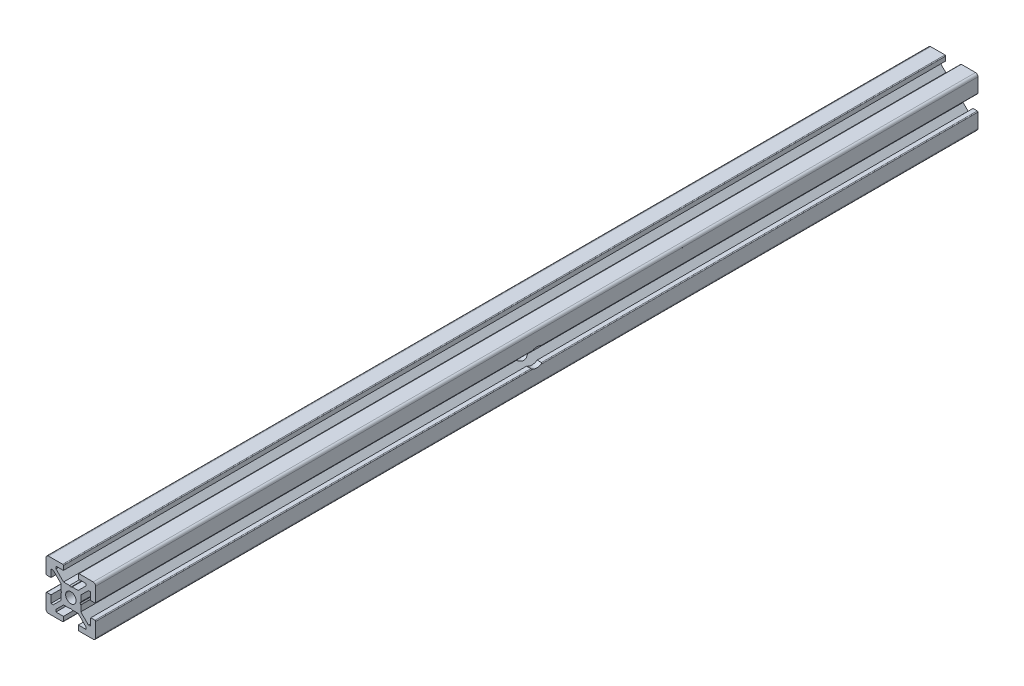
from build123d import *

# Parameters (mm, degrees)
BOSS_EXTRUDE1_DEPTH     = 355
SKETCH2_W               = 355
SKETCH2_H               = 2.1
SKETCH3_R               = 3.6751
CUT_EXTRUDE1_DEPTH      = 10
CUT_EXTRUDE1_DEPTH_BACK = 10


with BuildPart() as part:
    # Sketch1 → Boss-Extrude1 (new body)
    with BuildSketch(Plane.XY):
        with BuildLine():
            Line((-10, 9), (-10, 3.29999995))
            ThreePointArc((-10, 3.29999995), (-9.912132049, 3.087867916), (-9.7, 3))
            Line((-9.7, 3), (-8, 3))
            Line((-8, 3), (-8, 6))
            Line((-8, 6), (-7.060677, 6))
            Line((-7.060677, 6), (-4, 2.93932965))
            Line((-4, 2.93932965), (-4, 0.519615242))
            Line((-4, 0.519615242), (-3.699996283, -6.437e-06))
            Line((-3.699996283, -6.437e-06), (-4, -0.519628117))
            Line((-4, -0.519628117), (-4, -2.93933725))
            Line((-4, -2.93933725), (-7.0606695, -6))
            Line((-7.0606695, -6), (-8, -6))
            Line((-8, -6), (-8, -3))
            Line((-8, -3), (-9.7, -3))
            ThreePointArc((-9.7, -3), (-9.912132049, -3.087867916), (-10, -3.29999995))
            Line((-10, -3.29999995), (-10, -9))
            ThreePointArc((-10, -9), (-9.707106781, -9.707106781), (-9, -10))
            Line((-9, -10), (-3.29999995, -10))
            ThreePointArc((-3.29999995, -10), (-3.087867916, -9.912132049), (-3, -9.7))
            Line((-3, -9.7), (-3, -8))
            Line((-3, -8), (-6, -8))
            Line((-6, -8), (-6, -7.0606515))
            Line((-6, -7.0606515), (-2.9393489, -4))
            Line((-2.9393489, -4), (-0.519615242, -4))
            Line((-0.519615242, -4), (6.437e-06, -3.699996283))
            Line((6.437e-06, -3.699996283), (0.519628117, -4))
            Line((0.519628117, -4), (2.9393227, -4))
            Line((2.9393227, -4), (6, -7.060677))
            Line((6, -7.060677), (6, -8))
            Line((6, -8), (3, -8))
            Line((3, -8), (3, -9.7))
            ThreePointArc((3, -9.7), (3.087867916, -9.912132049), (3.29999995, -10))
            Line((3.29999995, -10), (9, -10))
            ThreePointArc((9, -10), (9.707106781, -9.707106781), (10, -9))
            Line((10, -9), (10, -3.29999995))
            ThreePointArc((10, -3.29999995), (9.912132049, -3.087867916), (9.7, -3))
            Line((9.7, -3), (8, -3))
            Line((8, -3), (8, -6))
            Line((8, -6), (7.0606435, -6))
            Line((7.0606435, -6), (4, -2.9393482))
            Line((4, -2.9393482), (4, -0.519615242))
            Line((4, -0.519615242), (3.699996283, 6.437e-06))
            Line((3.699996283, 6.437e-06), (4, 0.519628117))
            Line((4, 0.519628117), (4, 2.9393401))
            Line((4, 2.9393401), (7.060651, 6))
            Line((7.060651, 6), (8, 6))
            Line((8, 6), (8, 3))
            Line((8, 3), (9.7, 3))
            ThreePointArc((9.7, 3), (9.912132049, 3.087867916), (10, 3.29999995))
            Line((10, 3.29999995), (10, 9))
            ThreePointArc((10, 9), (9.707106781, 9.707106781), (9, 10))
            Line((9, 10), (3.29999995, 10))
            ThreePointArc((3.29999995, 10), (3.087867916, 9.912132049), (3, 9.7))
            Line((3, 9.7), (3, 8))
            Line((3, 8), (6, 8))
            Line((6, 8), (6, 7.060669))
            Line((6, 7.060669), (2.9393308, 4))
            Line((2.9393308, 4), (0.519615242, 4))
            Line((0.519615242, 4), (-6.437e-06, 3.699996283))
            Line((-6.437e-06, 3.699996283), (-0.519628117, 4))
            Line((-0.519628117, 4), (-2.93935655, 4))
            Line((-2.93935655, 4), (-6, 7.0606435))
            Line((-6, 7.0606435), (-6, 8))
            Line((-6, 8), (-3, 8))
            Line((-3, 8), (-3, 9.7))
            ThreePointArc((-3, 9.7), (-3.087867966, 9.912132034), (-3.3, 10))
            Line((-3.3, 10), (-9, 10))
            ThreePointArc((-9, 10), (-9.707106781, 9.707106781), (-10, 9))
        make_face()
    extrude(amount=-BOSS_EXTRUDE1_DEPTH)

    # Sketch2 → Cut-Revolve1 (revolve, cut)
    with BuildSketch(Plane(origin=(0, 0, 0), x_dir=(0, 0, -1), z_dir=(1, 0, 0))):
        with Locations((177.5, 1.05)):
            Rectangle(SKETCH2_W, SKETCH2_H)
    revolve(axis=Axis((0, 0, -355), (0, 0, 1)), mode=Mode.SUBTRACT)

    # Sketch3 → Cut-Extrude1 (cut, two sides)
    with BuildSketch(Plane(origin=(0, 0, 0), x_dir=(0, 0, -1), z_dir=(1, 0, 0))) as cut_extrude1_sk:
        with Locations((177.5, 0)):
            Circle(SKETCH3_R)
    extrude(amount=CUT_EXTRUDE1_DEPTH, mode=Mode.SUBTRACT)
    extrude(cut_extrude1_sk.sketch, amount=-CUT_EXTRUDE1_DEPTH_BACK, mode=Mode.SUBTRACT)


solid = part.part
